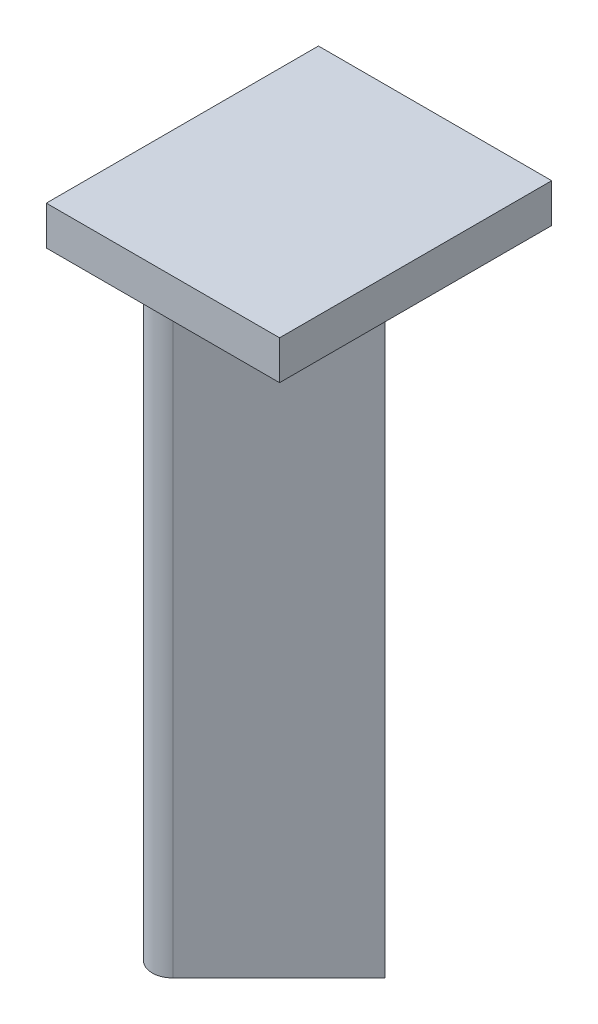
from build123d import *

# Parameters (mm, degrees)
BOSS_EXTRUDE1_DEPTH = 78
SKETCH2_W           = 30
SKETCH2_H           = 35
BOSS_EXTRUDE2_DEPTH = 5


with BuildPart() as part:
    # Sketch1 → Boss-Extrude1 (new body)
    with BuildSketch(Plane(origin=(0, 0, 0), x_dir=(1, 0, 0), z_dir=(0, 1, 0))):
        with BuildLine():
            Line((-6.024549776, 13.633018741), (7.608468966, 0))
            Line((7.608468966, 0), (-6.024549776, -13.633018741))
            ThreePointArc((-6.024549776, -13.633018741), (-9.814642123, -13.633018741), (-9.814642123, -9.842926394))
            Line((-9.814642123, -9.842926394), (-0.706968119, -0.735252391))
            ThreePointArc((-0.706968119, -0.735252391), (1.02, 0), (-0.706968119, 0.735252391))
            Line((-0.706968119, 0.735252391), (-9.814642123, 9.842926394))
            ThreePointArc((-9.814642123, 9.842926394), (-9.814642123, 13.633018741), (-6.024549776, 13.633018741))
        make_face()
    extrude(amount=BOSS_EXTRUDE1_DEPTH)

    # Sketch2 → Boss-Extrude2 (add)
    with BuildSketch(Plane(origin=(0, 78, 0), x_dir=(1, 0, 0), z_dir=(0, 1, 0))):
        with Locations((-2.479307664, -0.975058093)):
            Rectangle(SKETCH2_W, SKETCH2_H)
    extrude(amount=BOSS_EXTRUDE2_DEPTH)


solid = part.part
